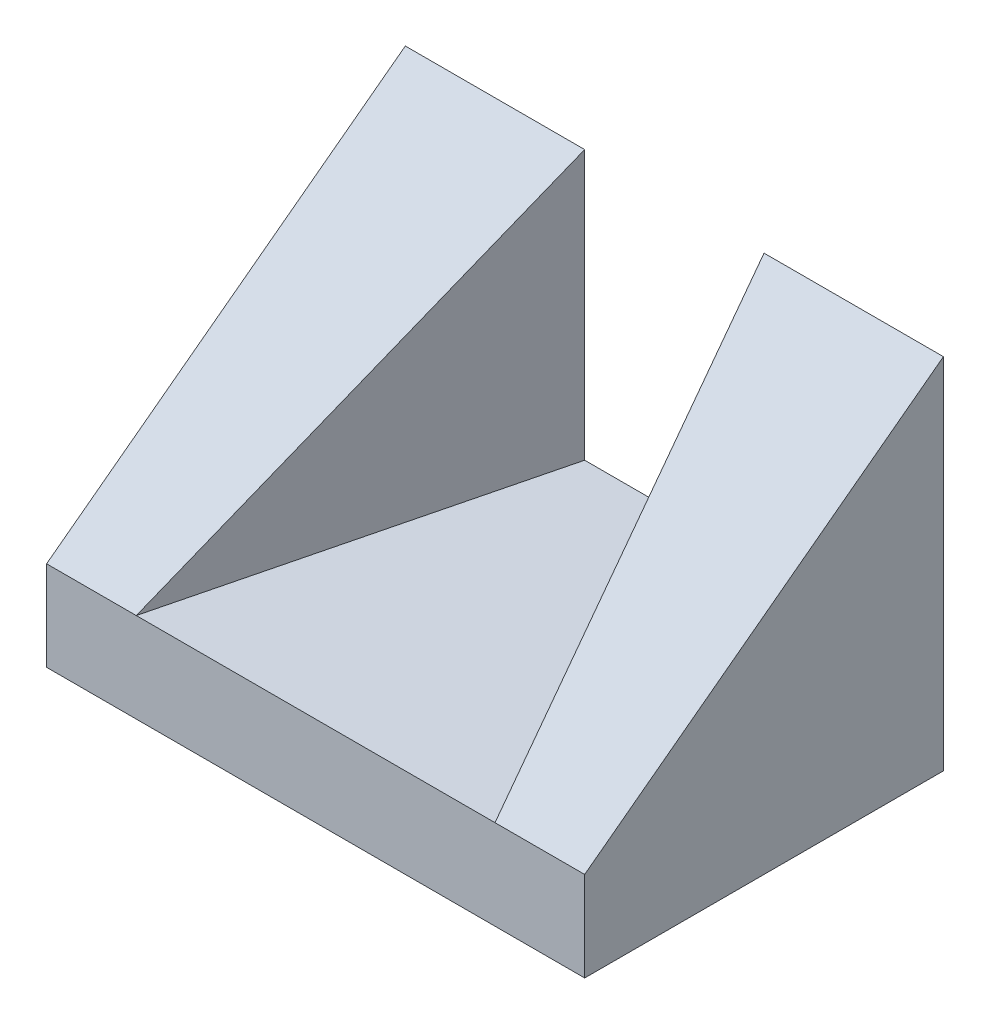
from build123d import *

# Parameters (mm, degrees)
SKETCH_1_W          = 30
SKETCH_1_H          = 20
EXTRUDE_1_DEPTH     = 5
EXTRUDE_2_DEPTH     = 20
CUT_EXTRUDE_1_DEPTH = 45


with BuildPart() as part:
    # 草圖1 → 填料-伸長1 (new body)
    with BuildSketch(Plane(origin=(0, 0, 0), x_dir=(1, 0, 0), z_dir=(0, 1, 0))):
        Rectangle(SKETCH_1_W, SKETCH_1_H)
    extrude(amount=EXTRUDE_1_DEPTH)

    # 草圖1<3> → 填料-伸長2 (add)
    with BuildSketch(Plane(origin=(0, 0, 0), x_dir=(1, 0, 0), z_dir=(0, 1, 0))):
        Polygon((-10, -10), (-5, 10), (-15, 10), (-15, -10), align=None)
        Polygon((15, 10), (5, 10), (10, -10), (15, -10), align=None)
    extrude(amount=EXTRUDE_2_DEPTH)

    # 草圖2 → 除料-伸長1 (cut)
    with BuildSketch(Plane(origin=(15, 0, 0), x_dir=(0, 0, -1), z_dir=(1, 0, 0))):
        Polygon((10, 20), (-10, 5), (-10, 20), align=None)
    extrude(amount=-CUT_EXTRUDE_1_DEPTH, mode=Mode.SUBTRACT)


solid = part.part
